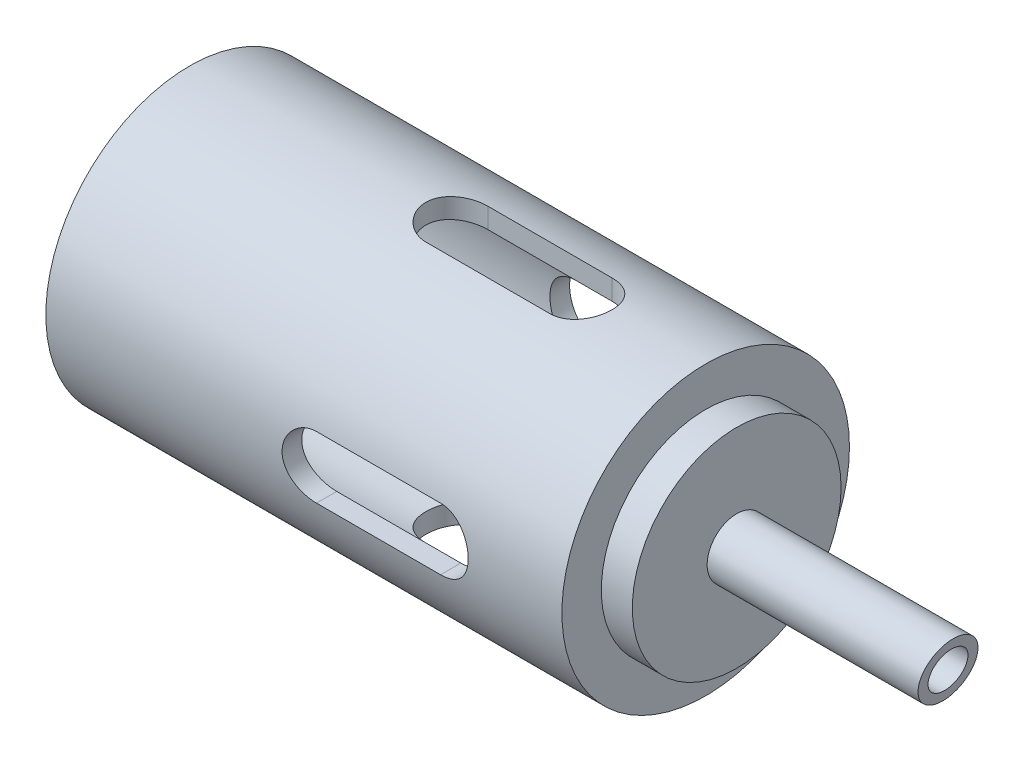
from build123d import *

# Parameters (mm, degrees)
CORTAR_EXTRUIR1_DEPTH      = 12.5875
CORTAR_EXTRUIR1_DEPTH_BACK = 12.5875
CORTAR_EXTRUIR2_DEPTH      = 12.5875001
CORTAR_EXTRUIR2_DEPTH_BACK = 12.5875001
CORTAR_EXTRUIR3_DEPTH      = 12.5875001
CORTAR_EXTRUIR3_DEPTH_BACK = 12.5875001


with BuildPart() as part:
    # Croquis1 → Revolución1 (revolve)
    with BuildSketch(Plane.XY):
        Polygon((-61.538063792, 11.5875), (-19.948063792, 11.5875), (-19.948063792, 8.4125), (-17.448063792, 8.4125), (-17.448063792, 2.38125), (0, 2.38125), (0, 1.5875), (-17.448063792, 1.5875), (-21.538063792, 1.5875), (-21.538063792, 10), (-61.538063792, 10), align=None)
    revolve(axis=Axis((0, 0, 0), (-1, 0, 0)))

    # Croquis2 → Cortar-Extruir1 (cut, two sides)
    with BuildSketch(Plane.XY) as cortar_extruir1_sk:
        with BuildLine():
            Line((-40, 2.5), (-30, 2.5))
            ThreePointArc((-30, 2.5), (-27.5, 0), (-30, -2.5))
            Line((-30, -2.5), (-40, -2.5))
            ThreePointArc((-40, -2.5), (-42.5, 0), (-40, 2.5))
        make_face()
    extrude(amount=CORTAR_EXTRUIR1_DEPTH, mode=Mode.SUBTRACT)
    extrude(cortar_extruir1_sk.sketch, amount=-CORTAR_EXTRUIR1_DEPTH_BACK, mode=Mode.SUBTRACT)

    # Croquis3 → Cortar-Extruir2 (cut, two sides)
    with BuildSketch(Plane(origin=(0, 0, 0), x_dir=(1, 0, 0), z_dir=(0, 1, 0))) as cortar_extruir2_sk:
        with BuildLine():
            Line((-40, 2.5), (-30, 2.5))
            ThreePointArc((-30, 2.5), (-27.5, 0), (-30, -2.5))
            Line((-30, -2.5), (-40, -2.5))
            ThreePointArc((-40, -2.5), (-42.5, 0), (-40, 2.5))
        make_face()
    extrude(amount=CORTAR_EXTRUIR2_DEPTH, mode=Mode.SUBTRACT)
    extrude(cortar_extruir2_sk.sketch, amount=-CORTAR_EXTRUIR2_DEPTH_BACK, mode=Mode.SUBTRACT)

    # Croquis4 → Cortar-Extruir3 (cut, two sides)
    with BuildSketch(Plane.XY) as cortar_extruir3_sk:
        Polygon((0, 2.38125), (-0.839757246, -2.38125), (0, -2.38125), align=None)
    extrude(amount=CORTAR_EXTRUIR3_DEPTH, mode=Mode.SUBTRACT)
    extrude(cortar_extruir3_sk.sketch, amount=-CORTAR_EXTRUIR3_DEPTH_BACK, mode=Mode.SUBTRACT)


solid = part.part
